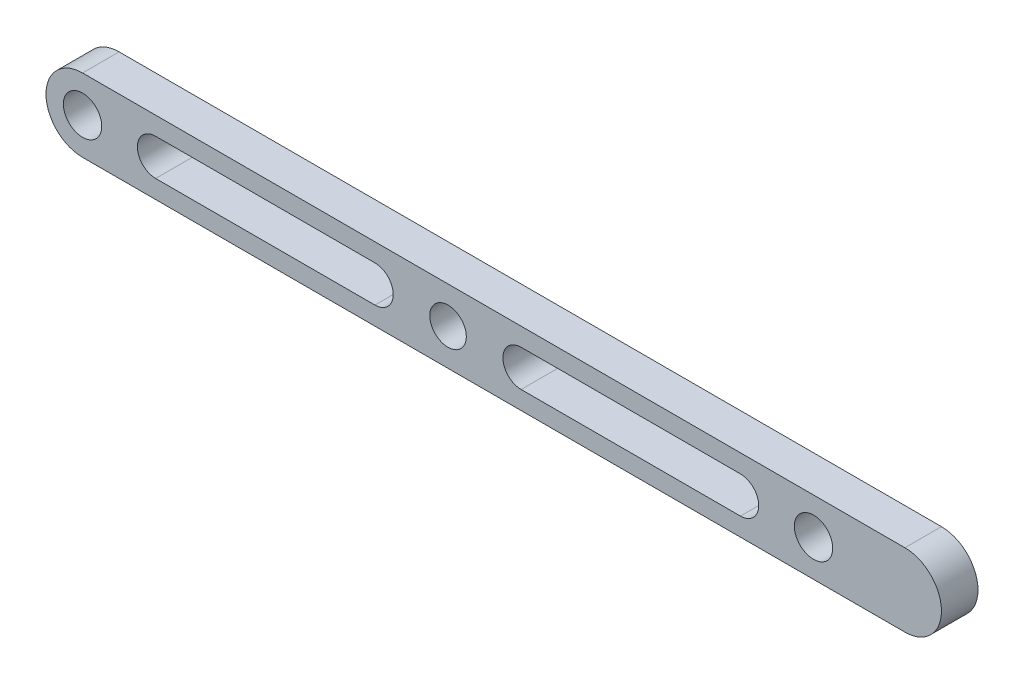
from build123d import *

# Parameters (mm, degrees)
SKETCH_1_R          = 5.25
EXTRUDE_1_DEPTH     = 10
SKETCH_2_R          = 5
CUT_EXTRUDE_1_DEPTH = 10
CUT_EXTRUDE_2_DEPTH = 10


with BuildPart() as part:
    # 草图1 → 凸台-拉伸1 (new body)
    with BuildSketch(Plane.XY):
        with BuildLine():
            Line((-100, 10), (100, 10))
            Line((100, 10), (125, 10))
            ThreePointArc((125, 10), (135, 0), (125, -10))
            Line((125, -10), (100, -10))
            Line((100, -10), (-100, -10))
            ThreePointArc((-100, -10), (-110, 0), (-100, 10))
        make_face()
        with Locations((-100, 0)):
            Circle(SKETCH_1_R, mode=Mode.SUBTRACT)
        with Locations((100, 0)):
            Circle(SKETCH_1_R, mode=Mode.SUBTRACT)
    extrude(amount=EXTRUDE_1_DEPTH)

    # 草图2 → 切除-拉伸1 (cut)
    with BuildSketch(Plane.XY.offset(10)):
        Circle(SKETCH_2_R)
    extrude(amount=-CUT_EXTRUDE_1_DEPTH, mode=Mode.SUBTRACT)

    # 草图4 → 切除-拉伸2 (cut)
    with BuildSketch(Plane.XY.offset(10)):
        with BuildLine():
            Line((-80, 5), (-20, 5))
            ThreePointArc((-20, 5), (-15, 0), (-20, -5))
            Line((-20, -5), (-80, -5))
            ThreePointArc((-80, -5), (-85, 0), (-80, 5))
        make_face()
        with BuildLine():
            Line((20, 5), (80, 5))
            ThreePointArc((80, 5), (85, 0), (80, -5))
            Line((80, -5), (20, -5))
            ThreePointArc((20, -5), (15, 0), (20, 5))
        make_face()
    extrude(amount=-CUT_EXTRUDE_2_DEPTH, mode=Mode.SUBTRACT)


solid = part.part
